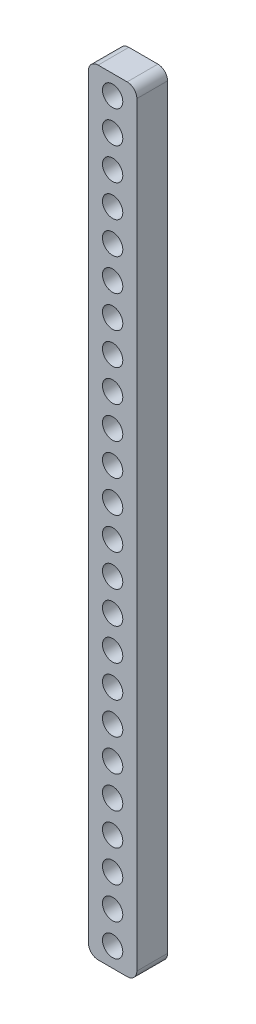
from build123d import *

# Parameters (mm, degrees)
SKETCH1_R           = 2.1
BOSS_EXTRUDE1_DEPTH = 6.35


with BuildPart() as part:
    # Sketch1 → Boss-Extrude1 (new body)
    with BuildSketch(Plane.XY):
        with BuildLine():
            Line((3, -80), (-3, -80))
            ThreePointArc((-3, -80), (-4.414213562, -79.414213562), (-5, -78))
            Line((-5, -78), (-5, 78))
            ThreePointArc((-5, 78), (-4.414213562, 79.414213562), (-3, 80))
            Line((-3, 80), (3, 80))
            ThreePointArc((3, 80), (4.414213562, 79.414213562), (5, 78))
            Line((5, 78), (5, -78))
            ThreePointArc((5, -78), (4.414213562, -79.414213562), (3, -80))
        make_face()
        with Locations((0, 76)):
            Circle(SKETCH1_R, mode=Mode.SUBTRACT)
        with Locations((0, 69.391304348)):
            Circle(SKETCH1_R, mode=Mode.SUBTRACT)
        with Locations((0, 62.782608696)):
            Circle(SKETCH1_R, mode=Mode.SUBTRACT)
        with Locations((0, 56.173913043)):
            Circle(SKETCH1_R, mode=Mode.SUBTRACT)
        with Locations((0, 49.565217391)):
            Circle(SKETCH1_R, mode=Mode.SUBTRACT)
        with Locations((0, 42.956521739)):
            Circle(SKETCH1_R, mode=Mode.SUBTRACT)
        with Locations((0, 36.347826087)):
            Circle(SKETCH1_R, mode=Mode.SUBTRACT)
        with Locations((0, 29.739130435)):
            Circle(SKETCH1_R, mode=Mode.SUBTRACT)
        with Locations((0, 23.130434783)):
            Circle(SKETCH1_R, mode=Mode.SUBTRACT)
        with Locations((0, 16.52173913)):
            Circle(SKETCH1_R, mode=Mode.SUBTRACT)
        with Locations((0, 9.913043478)):
            Circle(SKETCH1_R, mode=Mode.SUBTRACT)
        with Locations((0, 3.304347826)):
            Circle(SKETCH1_R, mode=Mode.SUBTRACT)
        with Locations((0, -3.304347826)):
            Circle(SKETCH1_R, mode=Mode.SUBTRACT)
        with Locations((0, -9.913043478)):
            Circle(SKETCH1_R, mode=Mode.SUBTRACT)
        with Locations((0, -16.52173913)):
            Circle(SKETCH1_R, mode=Mode.SUBTRACT)
        with Locations((0, -23.130434783)):
            Circle(SKETCH1_R, mode=Mode.SUBTRACT)
        with Locations((0, -29.739130435)):
            Circle(SKETCH1_R, mode=Mode.SUBTRACT)
        with Locations((0, -36.347826087)):
            Circle(SKETCH1_R, mode=Mode.SUBTRACT)
        with Locations((0, -42.956521739)):
            Circle(SKETCH1_R, mode=Mode.SUBTRACT)
        with Locations((0, -49.565217391)):
            Circle(SKETCH1_R, mode=Mode.SUBTRACT)
        with Locations((0, -56.173913043)):
            Circle(SKETCH1_R, mode=Mode.SUBTRACT)
        with Locations((0, -62.782608696)):
            Circle(SKETCH1_R, mode=Mode.SUBTRACT)
        with Locations((0, -69.391304348)):
            Circle(SKETCH1_R, mode=Mode.SUBTRACT)
        with Locations((0, -76)):
            Circle(SKETCH1_R, mode=Mode.SUBTRACT)
    extrude(amount=BOSS_EXTRUDE1_DEPTH)


solid = part.part
